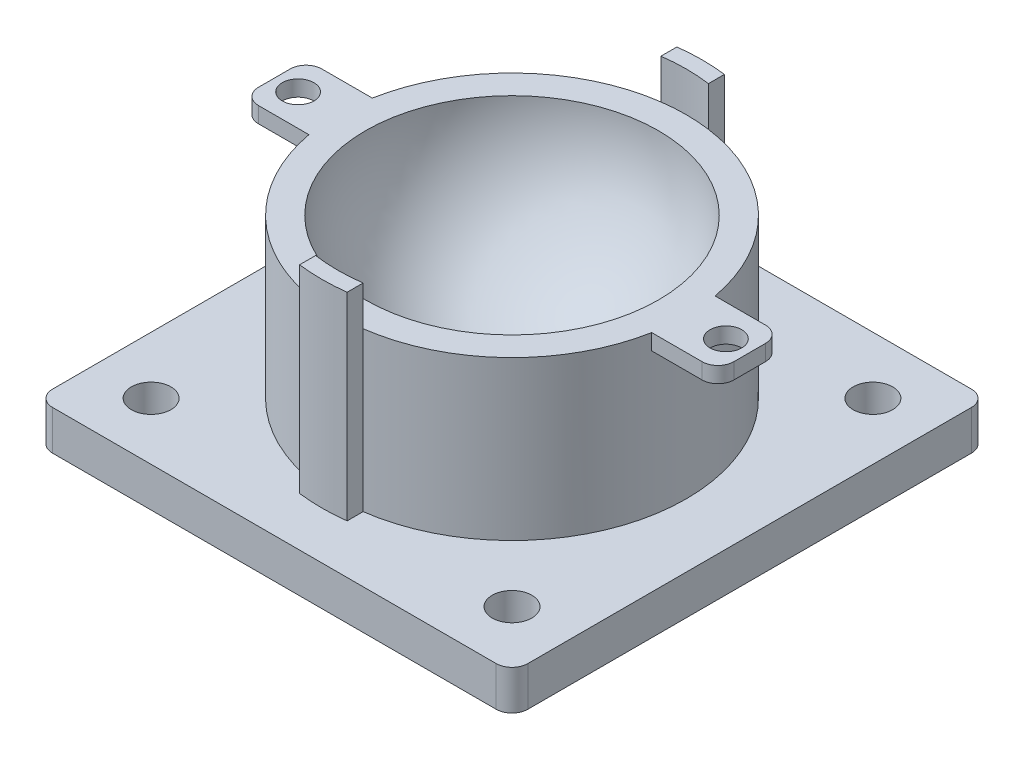
from build123d import *

# Parameters (mm, degrees)
SKETCH1_W           = 60
SKETCH1_H           = 60
SKETCH1_R           = 2.5
SKETCH1_R_2         = 22
SKETCH1_R_3         = 18.5
BOSS_EXTRUDE1_DEPTH = 5
BOSS_EXTRUDE2_START = 5
SKETCH1_3_R         = 22
SKETCH1_3_R_2       = 18.5
BOSS_EXTRUDE2_DEPTH = 20
FILLET1_R           = 2
BOSS_EXTRUDE6_DEPTH = 25
SKETCH5_R           = 2
BOSS_EXTRUDE7_DEPTH = 2


with BuildPart() as part:
    # Sketch1 → Boss-Extrude1 (new body)
    with BuildSketch(Plane(origin=(0, 0, 0), x_dir=(1, 0, 0), z_dir=(0, 1, 0))):
        Rectangle(SKETCH1_W, SKETCH1_H)
        with Locations(Location((22.778174593, 22.778174593, 0), (0, 0, 270))):
            Circle(SKETCH1_R, mode=Mode.SUBTRACT)
        with Locations(Location((22.778174593, -22.778174593, 0), (0, 0, 270))):
            Circle(SKETCH1_R, mode=Mode.SUBTRACT)
        with Locations(Location((-22.778174593, -22.778174593, 0), (0, 0, 270))):
            Circle(SKETCH1_R, mode=Mode.SUBTRACT)
        Circle(SKETCH1_R_2, mode=Mode.SUBTRACT)
        with Locations(Location((-22.778174593, 22.778174593, 0), (0, 0, 270))):
            Circle(SKETCH1_R, mode=Mode.SUBTRACT)
        Circle(SKETCH1_R_2)
        Circle(SKETCH1_R_3, mode=Mode.SUBTRACT)
        Circle(SKETCH1_R_3)
    extrude(amount=BOSS_EXTRUDE1_DEPTH)

    # Sketch1_3 → Boss-Extrude2 (add)
    with BuildSketch(Plane(origin=(0, 0, 0), x_dir=(1, 0, 0), z_dir=(0, 1, 0)).offset(BOSS_EXTRUDE2_START)):
        with Locations(Location((0, 0, 0), (0, 0, 270))):
            Circle(SKETCH1_3_R)
        Circle(SKETCH1_3_R_2, mode=Mode.SUBTRACT)
        Circle(SKETCH1_3_R_2)
    extrude(amount=BOSS_EXTRUDE2_DEPTH)

    # Sketch3 → Cut-Revolve4 (revolve, cut)
    with BuildSketch(Plane.XY):
        with BuildLine():
            Line((0, 16.001538563), (0, 25))
            Line((0, 25), (-18.5, 25))
            ThreePointArc((-18.5, 25), (-17.906501611, 20.351645447), (-16.164086481, 16.001538563))
            Line((-16.164086481, 16.001538563), (0, 16.001538563))
        make_face()
        with BuildLine():
            Line((0, 6.5), (0, 16.001538563))
            Line((0, 16.001538563), (-16.164086481, 16.001538563))
            ThreePointArc((-16.164086481, 16.001538563), (-9.374925691, 9.051308258), (0, 6.5))
        make_face()
    revolve(axis=Axis((0, 6.5, 0), (0, 1, 0)), mode=Mode.SUBTRACT)

    # Fillet1
    fillet1_edges = [part.edges().sort_by_distance(p)[0] for p in [
        (-30, 2.5, 30),
        (-30, 2.5, -30),
        (30, 2.5, -30),
        (30, 2.5, 30),
    ]]
    fillet(fillet1_edges, radius=FILLET1_R)

    # Sketch4 → Boss-Extrude6 (add)
    with BuildSketch(Plane(origin=(0, 5, 0), x_dir=(1, 0, 0), z_dir=(0, 1, 0))):
        with BuildLine():
            ThreePointArc((3, 23.8117618), (0, 24), (-3, 23.8117618))
            Line((-3, 23.8117618), (-3, 21.794494718))
            ThreePointArc((-3, 21.794494718), (0, 22), (3, 21.794494718))
            Line((3, 21.794494718), (3, 23.8117618))
        make_face()
        with BuildLine():
            Line((-3, -21.794494718), (-3, -23.8117618))
            ThreePointArc((-3, -23.8117618), (0, -24), (3, -23.8117618))
            Line((3, -23.8117618), (3, -21.794494718))
            ThreePointArc((3, -21.794494718), (0, -22), (-3, -21.794494718))
        make_face()
    extrude(amount=BOSS_EXTRUDE6_DEPTH)

    # Sketch5 → Boss-Extrude7 (add)
    with BuildSketch(Plane(origin=(0, 25, 0), x_dir=(1, 0, 0), z_dir=(0, 1, 0))):
        with BuildLine():
            ThreePointArc((30, 2), (29.414213562, 3.414213562), (28, 4))
            Line((28, 4), (21.633307653, 4))
            ThreePointArc((21.633307653, 4), (22, 0), (21.633307653, -4))
            Line((21.633307653, -4), (28, -4))
            ThreePointArc((28, -4), (29.414213562, -3.414213562), (30, -2))
            Line((30, -2), (30, 2))
        make_face()
        with Locations(Location((27, 0, 0), (0, 0, 270))):
            Circle(SKETCH5_R, mode=Mode.SUBTRACT)
        with BuildLine():
            ThreePointArc((-21.633307653, -4), (-22, 0), (-21.633307653, 4))
            Line((-21.633307653, 4), (-28, 4))
            ThreePointArc((-28, 4), (-29.414213562, 3.414213562), (-30, 2))
            Line((-30, 2), (-30, -2))
            ThreePointArc((-30, -2), (-29.414213562, -3.414213562), (-28, -4))
            Line((-28, -4), (-21.633307653, -4))
        make_face()
        with Locations(Location((-27, 0, 0), (0, 0, 270))):
            Circle(SKETCH5_R, mode=Mode.SUBTRACT)
    extrude(amount=-BOSS_EXTRUDE7_DEPTH)


solid = part.part
